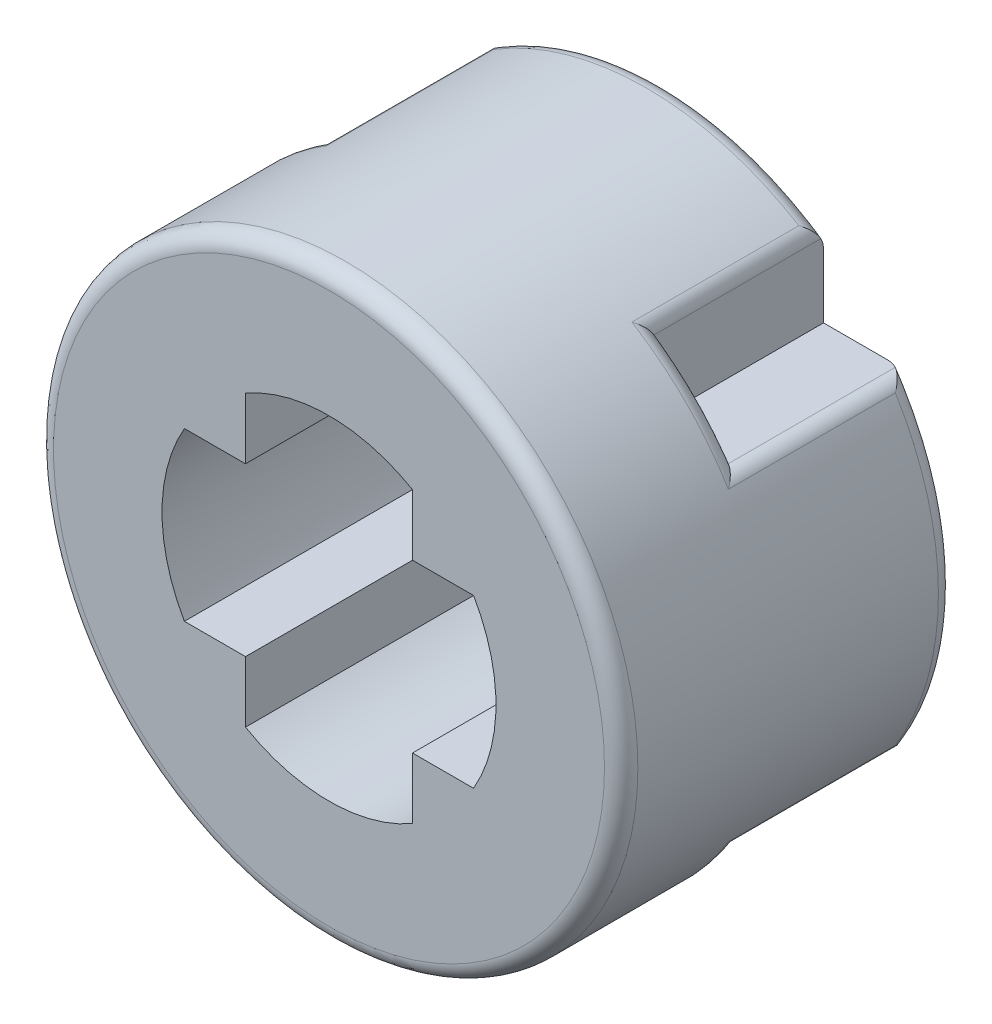
from build123d import *

# Parameters (mm, degrees)
SKETCH1_R           = 3.5
BOSS_EXTRUDE1_DEPTH = 4
SKETCH2_W           = 1
SKETCH2_H           = 1
CUT_EXTRUDE1_DEPTH  = 2
FILLET1_R           = 0.2


with BuildPart() as part:
    # Sketch1 → Boss-Extrude1 (new body)
    with BuildSketch(Plane.XY):
        Circle(SKETCH1_R)
        with BuildLine():
            Line((1, -1), (1.732050808, -1))
            ThreePointArc((1.732050808, -1), (2, 0), (1.732050808, 1))
            Line((1.732050808, 1), (1, 1))
            Line((1, 1), (1, 1.732050808))
            ThreePointArc((1, 1.732050808), (0, 2), (-1, 1.732050808))
            Line((-1, 1.732050808), (-1, 1))
            Line((-1, 1), (-1.732050808, 1))
            ThreePointArc((-1.732050808, 1), (-2, 0), (-1.732050808, -1))
            Line((-1.732050808, -1), (-1, -1))
            Line((-1, -1), (-1, -1.732050808))
            ThreePointArc((-1, -1.732050808), (0, -2), (1, -1.732050808))
            Line((1, -1.732050808), (1, -1))
        make_face(mode=Mode.SUBTRACT)
    extrude(amount=BOSS_EXTRUDE1_DEPTH)

    # Sketch2 → Cut-Extrude1 (cut)
    with BuildSketch(Plane(origin=(0, 0, 0), x_dir=(-1, 0, 0), z_dir=(0, 0, -1))):
        with Locations((-2.423839929, 2.423839929)):
            Rectangle(SKETCH2_W, SKETCH2_H)
        with Locations((-2.423839929, -2.423839929)):
            Rectangle(SKETCH2_W, SKETCH2_H)
        with Locations((2.423839929, -2.423839929)):
            Rectangle(SKETCH2_W, SKETCH2_H)
        with Locations((2.423839929, 2.423839929)):
            Rectangle(SKETCH2_W, SKETCH2_H)
    extrude(amount=-CUT_EXTRUDE1_DEPTH, mode=Mode.SUBTRACT)

    # Fillet1
    fillet1_edges = [part.edges().sort_by_distance(p)[0] for p in [
        (0, 3.5, 0),
        (-3.5, 0, 0),
        (0, -3.5, 0),
        (3.352867411, 1.004131528, 0),
        (2.474873734, 2.474873734, 2),
        (2.474873734, -2.474873734, 2),
        (-3.5, 0, 4),
        (-2.474873734, -2.474873734, 2),
        (-2.474873734, 2.474873734, 2),
        (-2.923839929, 1.923839929, 1),
        (-1.923839929, 2.923839929, 1),
        (-1.923839929, -2.923839929, 1),
        (-2.923839929, -1.923839929, 1),
        (2.923839929, -1.923839929, 1),
        (1.923839929, -2.923839929, 1),
        (2.923839929, 1.923839929, 1),
        (1.923839929, 2.923839929, 1),
    ]]
    fillet(fillet1_edges, radius=FILLET1_R)


solid = part.part
